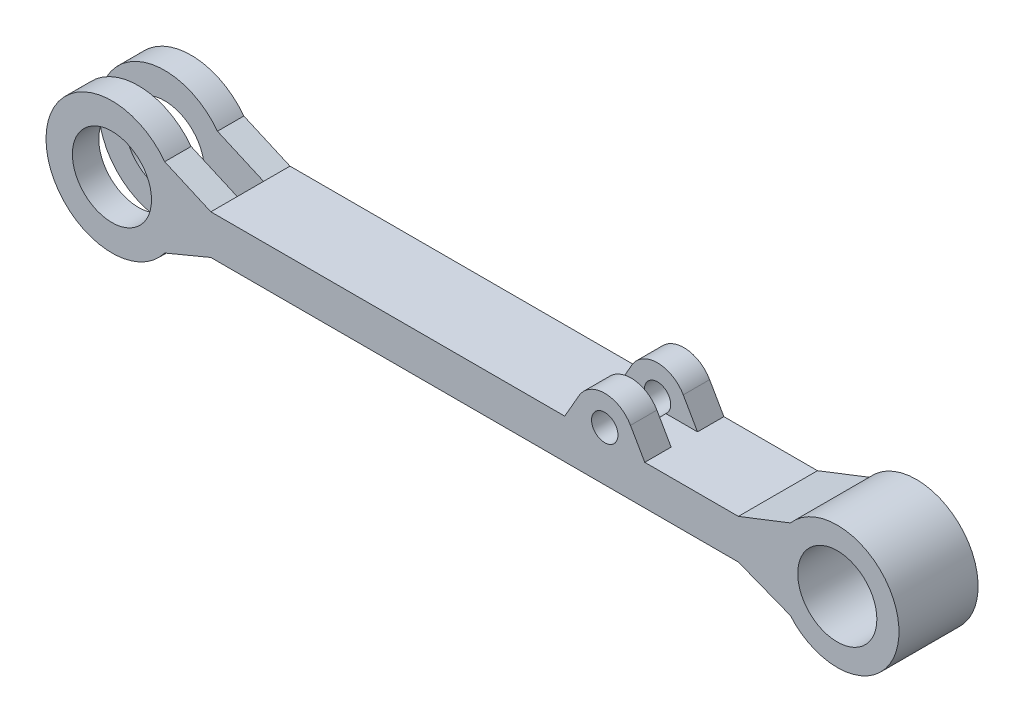
from build123d import *

# Parameters (mm, degrees)
SKETCH1_R           = 30
BOSS_EXTRUDE1_DEPTH = 60
SKETCH2_W           = 125
SKETCH2_H           = 20
CUT_EXTRUDE1_DEPTH  = 70
BOSS_EXTRUDE2_DEPTH = 60
SKETCH4_R           = 10
CUT_EXTRUDE2_DEPTH  = 61
SKETCH5_W           = 20
SKETCH5_H           = 30.196617065
CUT_EXTRUDE3_DEPTH  = 350


with BuildPart() as part:
    # Sketch1 → Boss-Extrude1 (new body)
    with BuildSketch(Plane.XY):
        with BuildLine():
            Line((200, 15), (-200, 15))
            Line((-200, 15), (-234.992965725, 30.413109921))
            ThreePointArc((-234.992965725, 30.413109921), (-325, 0.422491245), (-234.992965725, -29.568127431))
            Line((-234.992965725, -29.568127431), (-200, -15))
            Line((-200, -15), (200, -15))
            Line((200, -15), (239.447282721, -30.416066909))
            ThreePointArc((239.447282721, -30.416066909), (321.788169788, 0), (239.447282721, 30.416066909))
            Line((239.447282721, 30.416066909), (200, 15))
        make_face()
        with Locations((-275, 0.422491245)):
            Circle(SKETCH1_R, mode=Mode.SUBTRACT)
        with Locations((275, 0)):
            Circle(SKETCH1_R, mode=Mode.SUBTRACT)
    extrude(amount=BOSS_EXTRUDE1_DEPTH)

    # Sketch2 → Cut-Extrude1 (cut, symmetric)
    with BuildSketch(Plane(origin=(0, 15, 0), x_dir=(1, 0, 0), z_dir=(0, 1, 0))):
        with Locations((-262.5, -30)):
            Rectangle(SKETCH2_W, SKETCH2_H)
    extrude(amount=CUT_EXTRUDE1_DEPTH, both=True, mode=Mode.SUBTRACT)

    # Sketch3 → Boss-Extrude2 (add)
    with BuildSketch(Plane.XY.offset(60)):
        with BuildLine():
            ThreePointArc((118.204825436, 33.881006124), (98.681520352, 45.196617065), (79.158215269, 33.881006124))
            ThreePointArc((79.158215269, 33.881006124), (76.263820119, 24.619301704), (77.538860024, 15))
            Line((77.538860024, 15), (92.297001125, 15))
            ThreePointArc((92.297001125, 15), (98.681520352, 32.696617065), (105.066039579, 15))
            Line((105.066039579, 15), (119.824180681, 15))
            ThreePointArc((119.824180681, 15), (121.099220586, 24.619301704), (118.204825436, 33.881006124))
        make_face()
        with BuildLine():
            ThreePointArc((77.538860024, 15), (76.263820119, 24.619301704), (79.158215269, 33.881006124))
            Line((79.158215269, 33.881006124), (68.341782426, 15))
            Line((68.341782426, 15), (77.538860024, 15))
        make_face()
        with BuildLine():
            Line((129.021258279, 15), (118.204825436, 33.881006124))
            ThreePointArc((118.204825436, 33.881006124), (121.099220586, 24.619301704), (119.824180681, 15))
            Line((119.824180681, 15), (129.021258279, 15))
        make_face()
    extrude(amount=-BOSS_EXTRUDE2_DEPTH)

    # Sketch4 → Cut-Extrude2 (cut, through all)
    with BuildSketch(Plane.XY.offset(60)):
        with Locations((98.681520352, 22.696617065)):
            Circle(SKETCH4_R)
    extrude(amount=-CUT_EXTRUDE2_DEPTH, mode=Mode.SUBTRACT)

    # Sketch5 → Cut-Extrude3 (cut)
    with BuildSketch(Plane.ZY.offset(200)):
        with Locations((30, 30.098308533)):
            Rectangle(SKETCH5_W, SKETCH5_H)
    extrude(amount=-CUT_EXTRUDE3_DEPTH, mode=Mode.SUBTRACT)


solid = part.part
